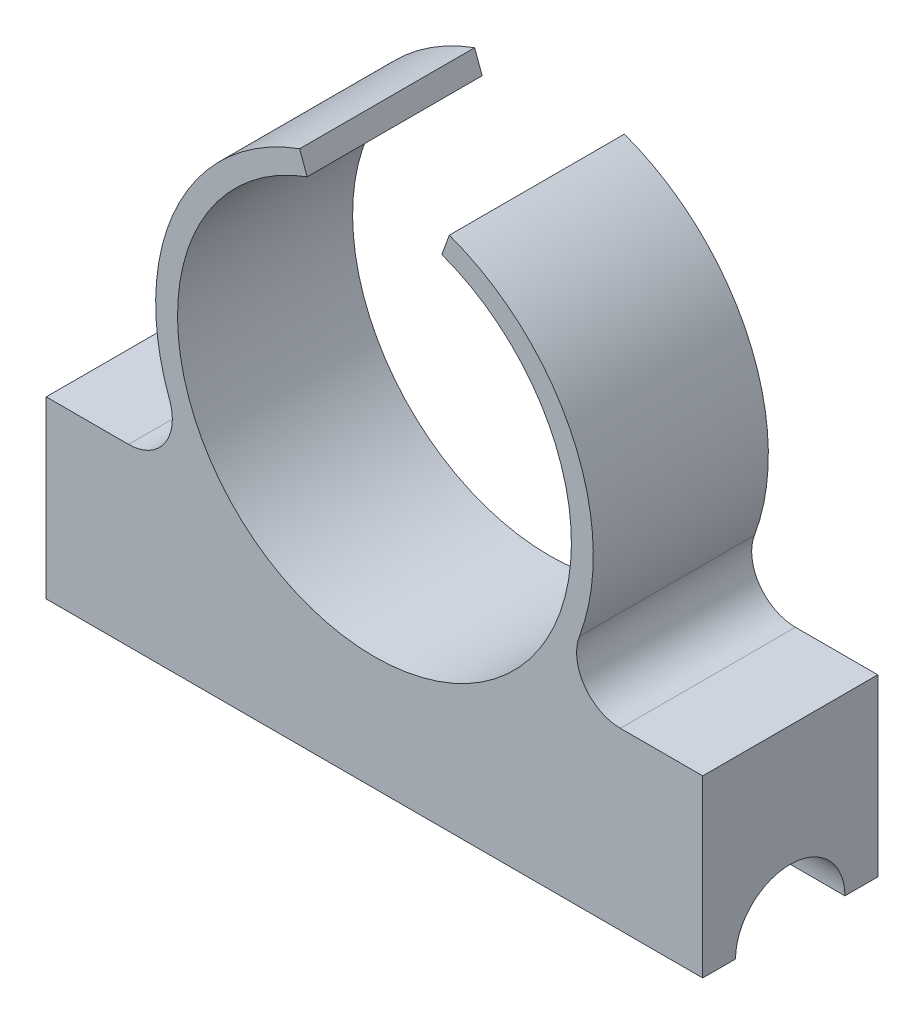
from build123d import *

# Parameters (mm, degrees)
BOSS_EXTRUDE1_DEPTH = 8
SKETCH2_R           = 9
CUT_EXTRUDE1_DEPTH  = 35
SKETCH3_W           = 0.5
SKETCH3_H           = 1.875425002
CUT_EXTRUDE2_DEPTH  = 25
SKETCH4_R           = 2.5
CUT_EXTRUDE3_DEPTH  = 110
SKETCH6_W           = 5
SKETCH6_H           = 7.147198513
CUT_EXTRUDE4_DEPTH  = 10
FILLET1_R           = 0.5
SKETCH8_W           = 8
SKETCH8_H           = 3
BOSS_EXTRUDE2_DEPTH = 30
SKETCH9_R           = 9
CUT_EXTRUDE5_DEPTH  = 30
FILLET2_R           = 2
CUT_EXTRUDE7_DEPTH  = 30


with BuildPart() as part:
    # Sketch1 → Boss-Extrude1 (new body)
    with BuildSketch(Plane.XY):
        with BuildLine():
            Line((3.89007335, 2.5), (15, 2.5))
            Line((15, 2.5), (15, -2.5))
            Line((15, -2.5), (-15, -2.5))
            Line((-15, -2.5), (-15, 2.5))
            Line((-15, 2.5), (-3.89007335, 2.5))
            ThreePointArc((-3.89007335, 2.5), (0, 21.71234657), (3.89007335, 2.5))
        make_face()
    extrude(amount=BOSS_EXTRUDE1_DEPTH)

    # Sketch2 → Cut-Extrude1 (cut)
    with BuildSketch(Plane.XY.offset(8)):
        with Locations((0, 11.71234657)):
            Circle(SKETCH2_R)
    extrude(amount=-CUT_EXTRUDE1_DEPTH, mode=Mode.SUBTRACT)

    # Sketch3 → Cut-Extrude2 (cut)
    with BuildSketch(Plane(origin=(0, 0, 0), x_dir=(-1, 0, 0), z_dir=(0, 0, -1))):
        with Locations((0, 21.521483579)):
            Rectangle(SKETCH3_W, SKETCH3_H)
    extrude(amount=-CUT_EXTRUDE2_DEPTH, mode=Mode.SUBTRACT)

    # Sketch4 → Cut-Extrude3 (cut)
    with BuildSketch(Plane(origin=(15, 0, 0), x_dir=(0, 0, -1), z_dir=(1, 0, 0))):
        with Locations((-4, -2.5)):
            Circle(SKETCH4_R)
    extrude(amount=-CUT_EXTRUDE3_DEPTH, mode=Mode.SUBTRACT)

    # Sketch6 → Cut-Extrude4 (cut)
    with BuildSketch(Plane.XY.offset(8)):
        with Locations((0, 22.731746569)):
            Rectangle(SKETCH6_W, SKETCH6_H)
    extrude(amount=-CUT_EXTRUDE4_DEPTH, mode=Mode.SUBTRACT)

    # Fillet1
    fillet1_edges = [part.edges().sort_by_distance(p)[0] for p in [
        (-3.89007335, 2.5, 4),
        (3.89007335, 2.5, 4),
    ]]
    fillet(fillet1_edges, radius=FILLET1_R)

    # Sketch8 → Boss-Extrude2 (add)
    with BuildSketch(Plane.ZY.offset(15)):
        with Locations((4, 4)):
            Rectangle(SKETCH8_W, SKETCH8_H)
    extrude(amount=-BOSS_EXTRUDE2_DEPTH)

    # Sketch9 → Cut-Extrude5 (cut)
    with BuildSketch(Plane(origin=(0, 0, 0), x_dir=(-1, 0, 0), z_dir=(0, 0, -1))):
        with Locations((0, 11.71234657)):
            Circle(SKETCH9_R)
    extrude(amount=-CUT_EXTRUDE5_DEPTH, mode=Mode.SUBTRACT)

    # Fillet2
    fillet2_edges = [part.edges().sort_by_distance(p)[0] for p in [
        (-7.836245918, 5.5, 4),
        (7.836245918, 5.5, 4),
    ]]
    fillet(fillet2_edges, radius=FILLET2_R)

    # Sketch10 → Cut-Extrude7 (cut)
    with BuildSketch(Plane(origin=(0, 0, 0), x_dir=(-1, 0, 0), z_dir=(0, 0, -1))):
        with BuildLine():
            Line((0, 11.71234657), (3.420201433, 21.109272778))
            ThreePointArc((3.420201433, 21.109272778), (0, 24.529474212), (-3.420201433, 21.109272778))
            Line((-3.420201433, 21.109272778), (0, 11.71234657))
        make_face()
    extrude(amount=-CUT_EXTRUDE7_DEPTH, mode=Mode.SUBTRACT)


solid = part.part
